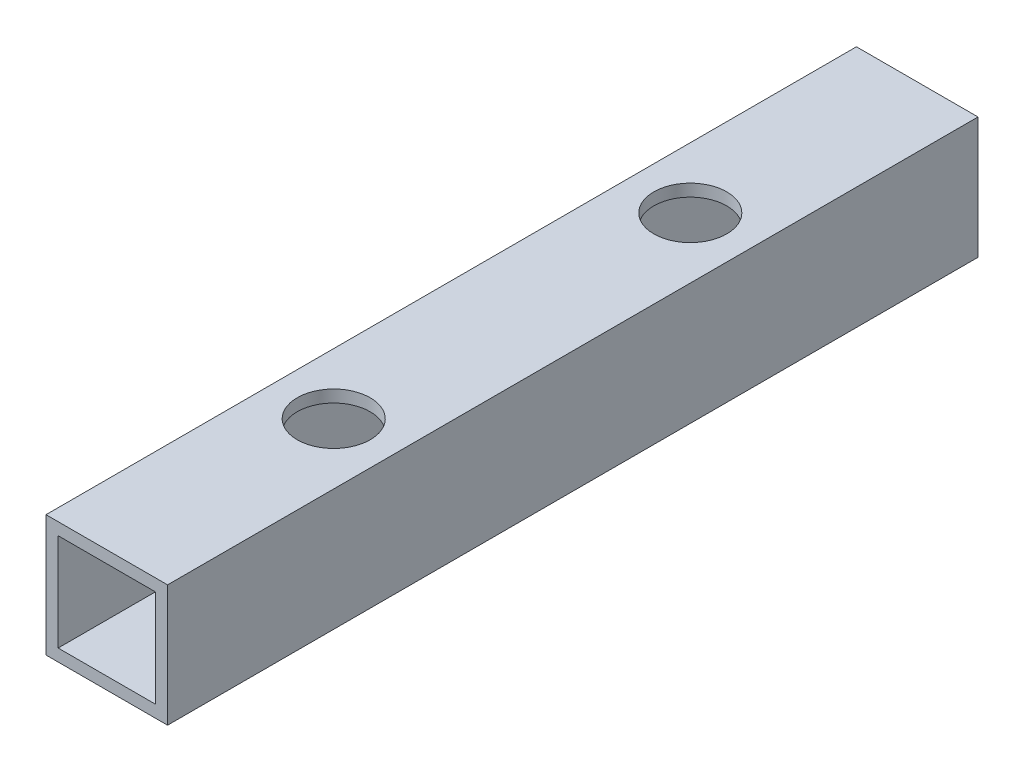
from build123d import *

# Parameters (mm, degrees)
SKETCH_1_W          = 15
SKETCH_1_H          = 15
SKETCH_1_W_2        = 12
SKETCH_1_H_2        = 12
EXTRUDE_1_DEPTH     = 100
SKETCH_2_R          = 4.5
CUT_EXTRUDE_1_DEPTH = 60


with BuildPart() as part:
    # ｽｹｯﾁ1 → ﾎﾞｽ - 押し出し1 (new body)
    with BuildSketch(Plane.XY):
        Rectangle(SKETCH_1_W, SKETCH_1_H)
        Rectangle(SKETCH_1_W_2, SKETCH_1_H_2, mode=Mode.SUBTRACT)
    extrude(amount=EXTRUDE_1_DEPTH)

    # ｽｹｯﾁ2 → ｶｯﾄ - 押し出し1 (cut)
    with BuildSketch(Plane(origin=(0, 7.5, 0), x_dir=(1, 0, 0), z_dir=(0, 1, 0))):
        with Locations((0, -72)):
            Circle(SKETCH_2_R)
        with Locations((0, -28)):
            Circle(SKETCH_2_R)
    extrude(amount=-CUT_EXTRUDE_1_DEPTH, mode=Mode.SUBTRACT)


solid = part.part
